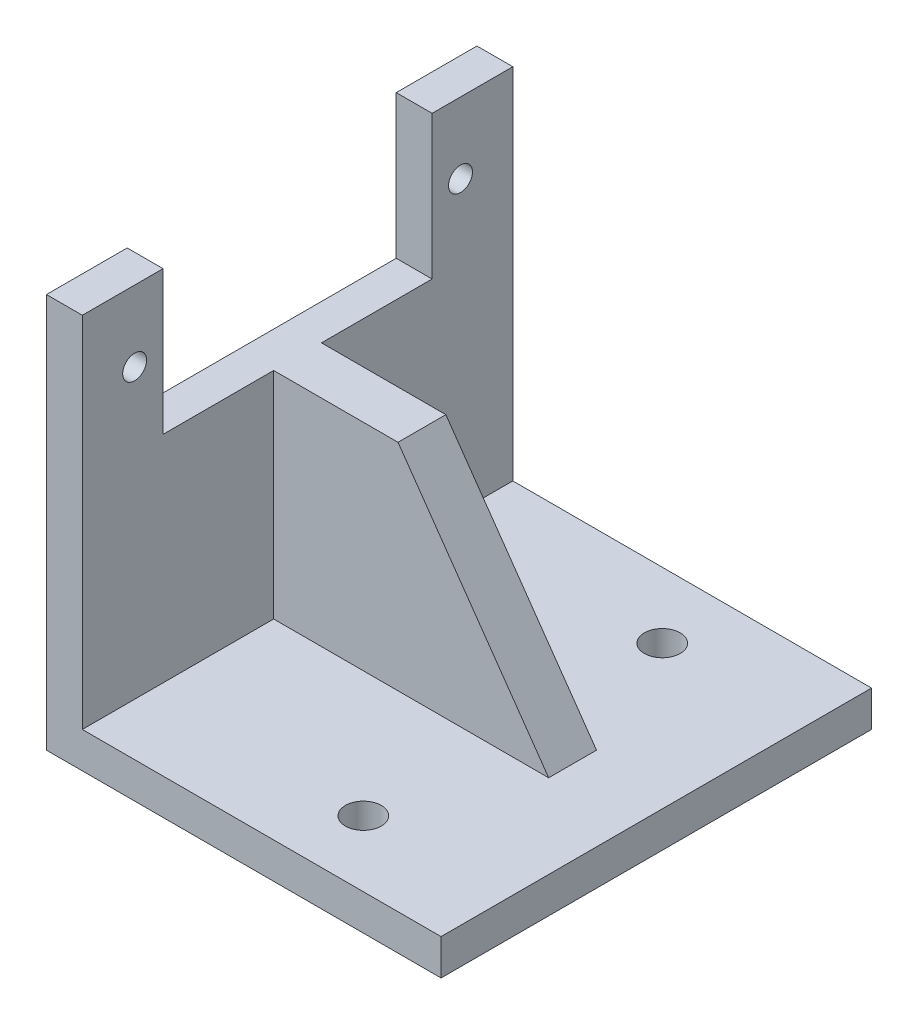
from build123d import *

# Parameters (mm, degrees)
EXTRUDE_THIN1_DEPTH = 18
SKETCH2_W           = 22.5
SKETCH2_H           = 12
CUT_EXTRUDE1_DEPTH  = 4
SKETCH3_R           = 1
CUT_EXTRUDE2_DEPTH  = 4
SKETCH6_W           = 23
SKETCH6_H           = 4
BOSS_EXTRUDE1_DEPTH = 18
CUT_EXTRUDE3_DEPTH  = 21
SKETCH8_R           = 1.5
CUT_EXTRUDE4_DEPTH  = 4


with BuildPart() as part:
    # Sketch1 → Extrude-Thin1 (new body, symmetric)
    with BuildSketch(Plane.XY):
        Polygon((30, 0), (0, 0), (0, 30), (-3, 30), (-3, -3), (30, -3), align=None)
    extrude(amount=EXTRUDE_THIN1_DEPTH, both=True)

    # Sketch2 → Cut-Extrude1 (cut, through all)
    with BuildSketch(Plane(origin=(0, 0, 0), x_dir=(0, 0, -1), z_dir=(1, 0, 0))):
        with Locations((0, 24)):
            Rectangle(SKETCH2_W, SKETCH2_H)
    extrude(amount=-CUT_EXTRUDE1_DEPTH, mode=Mode.SUBTRACT)

    # Sketch3 → Cut-Extrude2 (cut, through all)
    with BuildSketch(Plane(origin=(0, 0, 0), x_dir=(0, 0, -1), z_dir=(1, 0, 0))):
        with Locations((13.625, 24.069423531)):
            Circle(SKETCH3_R)
        with Locations((-13.625, 24.069423531)):
            Circle(SKETCH3_R)
    extrude(amount=-CUT_EXTRUDE2_DEPTH, mode=Mode.SUBTRACT)

    # Sketch6 → Boss-Extrude1 (add)
    with BuildSketch(Plane(origin=(0, 0, 0), x_dir=(1, 0, 0), z_dir=(0, 1, 0))):
        with Locations((11.5, 0)):
            Rectangle(SKETCH6_W, SKETCH6_H)
    extrude(amount=BOSS_EXTRUDE1_DEPTH)

    # Sketch7 → Cut-Extrude3 (cut, through all)
    with BuildSketch(Plane(origin=(0, 0, -2), x_dir=(-1, 0, 0), z_dir=(0, 0, -1))):
        Polygon((-10.399594351, 18), (-23, 18), (-23, 0), align=None)
    extrude(amount=-CUT_EXTRUDE3_DEPTH, mode=Mode.SUBTRACT)

    # Sketch8 → Cut-Extrude4 (cut, through all)
    with BuildSketch(Plane(origin=(0, 0, 0), x_dir=(1, 0, 0), z_dir=(0, 1, 0))):
        with Locations((18, 12.5)):
            Circle(SKETCH8_R)
        with Locations((18, -12.5)):
            Circle(SKETCH8_R)
    extrude(amount=-CUT_EXTRUDE4_DEPTH, mode=Mode.SUBTRACT)


solid = part.part
